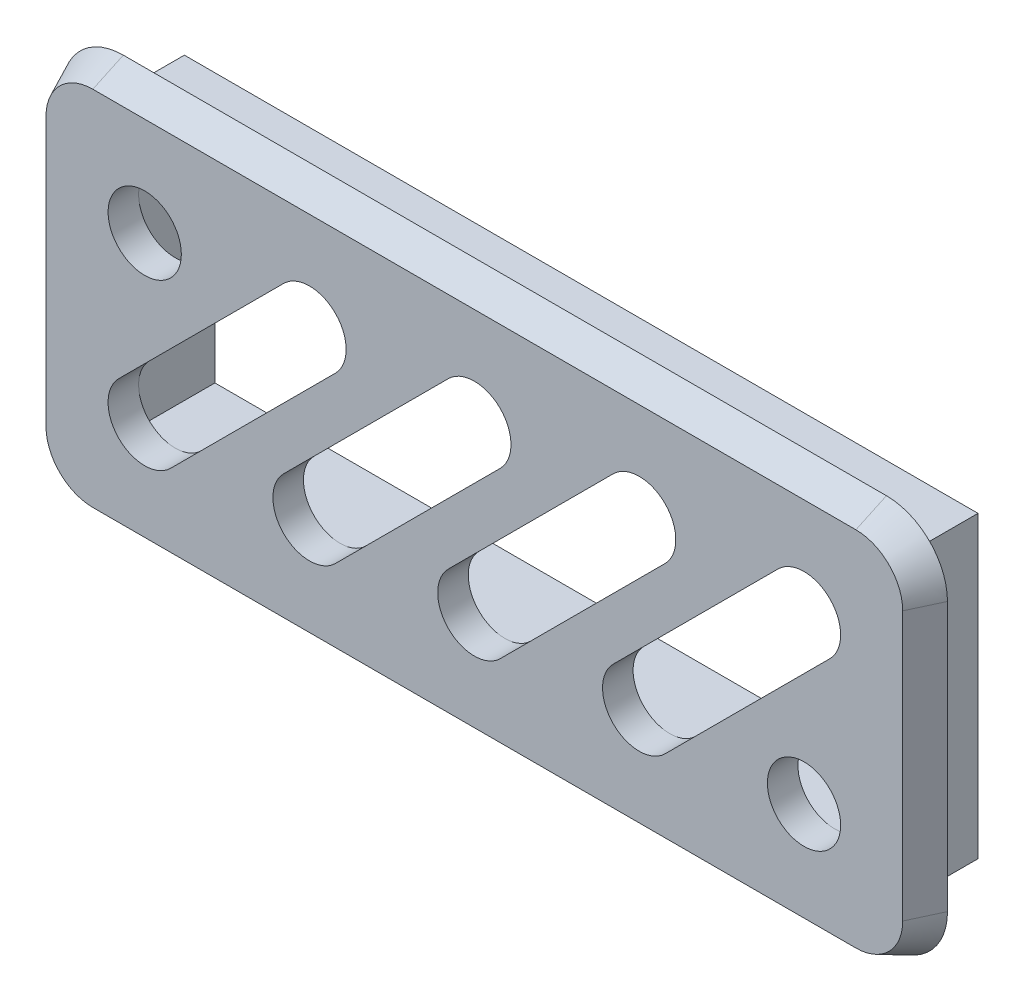
from build123d import *

# Parameters (mm, degrees)
SKETCH_1_W          = 26
SKETCH_1_H          = 9.8
SKETCH_1_W_2        = 24
SKETCH_1_H_2        = 7.8
EXTRUDE_1_DEPTH     = 2.5
EXTRUDE_2_DEPTH     = 1
EXTRUDE_2_TAPER     = 25
CUT_EXTRUDE_1_REACH = 3
SKETCH_3_R          = 1.2


with BuildPart() as part:
    # 草图1 → 凸台-拉伸1 (new body)
    with BuildSketch(Plane.XY):
        with Locations((20.66383505, -8.200793938)):
            Rectangle(SKETCH_1_W, SKETCH_1_H)
        with Locations((20.66383505, -8.200793938)):
            Rectangle(SKETCH_1_W_2, SKETCH_1_H_2, mode=Mode.SUBTRACT)
    extrude(amount=-EXTRUDE_1_DEPTH)

    # 草图2 → 凸台-拉伸2 (add)
    with BuildSketch(Plane.XY):
        with BuildLine():
            Line((35.16383505, -12.600793938), (35.16383505, -3.800793938))
            ThreePointArc((35.16383505, -3.800793938), (34.578048612, -2.386580376), (33.16383505, -1.800793938))
            Line((33.16383505, -1.800793938), (8.16383505, -1.800793938))
            ThreePointArc((8.16383505, -1.800793938), (6.749621488, -2.386580376), (6.16383505, -3.800793938))
            Line((6.16383505, -3.800793938), (6.16383505, -12.600793938))
            ThreePointArc((6.16383505, -12.600793938), (6.749621488, -14.015007501), (8.16383505, -14.600793938))
            Line((8.16383505, -14.600793938), (33.16383505, -14.600793938))
            ThreePointArc((33.16383505, -14.600793938), (34.578048612, -14.015007501), (35.16383505, -12.600793938))
        make_face()
    extrude(amount=EXTRUDE_2_DEPTH, taper=EXTRUDE_2_TAPER)

    # 草图3 → 切除-拉伸1 (cut, up to next)
    with BuildSketch(Plane(origin=(0, 0, 0), x_dir=(-1, 0, 0), z_dir=(0, 0, -1)), mode=Mode.PRIVATE) as cut_extrude_1_sk1:
        with Locations((-31.46383505, -10.900793938)):
            Circle(SKETCH_3_R)
    cut_extrude_1_tool1 = extrude(cut_extrude_1_sk1.sketch, amount=-CUT_EXTRUDE_1_REACH, mode=Mode.PRIVATE) & part.part
    add(cut_extrude_1_tool1.solids().sort_by_distance((31.463835, -10.900794, 0))[0], mode=Mode.SUBTRACT)
    # 草图3 → 切除-拉伸1 (cut, up to next)
    with BuildSketch(Plane(origin=(0, 0, 0), x_dir=(-1, 0, 0), z_dir=(0, 0, -1)), mode=Mode.PRIVATE) as cut_extrude_1_sk2:
        with Locations((-9.86383505, -5.500793938)):
            Circle(SKETCH_3_R)
    cut_extrude_1_tool2 = extrude(cut_extrude_1_sk2.sketch, amount=-CUT_EXTRUDE_1_REACH, mode=Mode.PRIVATE) & part.part
    add(cut_extrude_1_tool2.solids().sort_by_distance((9.863835, -5.500794, 0))[0], mode=Mode.SUBTRACT)
    # 草图3 → 切除-拉伸1 (cut, up to next)
    with BuildSketch(Plane(origin=(0, 0, 0), x_dir=(-1, 0, 0), z_dir=(0, 0, -1)), mode=Mode.PRIVATE) as cut_extrude_1_sk3:
        with BuildLine():
            Line((-30.615306913, -4.652265801), (-25.215306913, -10.052265801))
            ThreePointArc((-25.215306913, -10.052265801), (-25.215306913, -11.749322076), (-26.912363188, -11.749322076))
            Line((-26.912363188, -11.749322076), (-32.312363188, -6.349322076))
            ThreePointArc((-32.312363188, -6.349322076), (-32.312363188, -4.652265801), (-30.615306913, -4.652265801))
        make_face()
    cut_extrude_1_tool3 = extrude(cut_extrude_1_sk3.sketch, amount=-CUT_EXTRUDE_1_REACH, mode=Mode.PRIVATE) & part.part
    add(cut_extrude_1_tool3.solids().sort_by_distance((28.763835, -8.200794, 0))[0], mode=Mode.SUBTRACT)
    # 草图3 → 切除-拉伸1 (cut, up to next)
    with BuildSketch(Plane(origin=(0, 0, 0), x_dir=(-1, 0, 0), z_dir=(0, 0, -1)), mode=Mode.PRIVATE) as cut_extrude_1_sk4:
        with BuildLine():
            Line((-25.215306913, -4.652265801), (-19.815306913, -10.052265801))
            ThreePointArc((-19.815306913, -10.052265801), (-19.815306913, -11.749322076), (-21.512363188, -11.749322076))
            Line((-21.512363188, -11.749322076), (-26.912363188, -6.349322076))
            ThreePointArc((-26.912363188, -6.349322076), (-26.912363188, -4.652265801), (-25.215306913, -4.652265801))
        make_face()
    cut_extrude_1_tool4 = extrude(cut_extrude_1_sk4.sketch, amount=-CUT_EXTRUDE_1_REACH, mode=Mode.PRIVATE) & part.part
    add(cut_extrude_1_tool4.solids().sort_by_distance((23.363835, -8.200794, 0))[0], mode=Mode.SUBTRACT)
    # 草图3 → 切除-拉伸1 (cut, up to next)
    with BuildSketch(Plane(origin=(0, 0, 0), x_dir=(-1, 0, 0), z_dir=(0, 0, -1)), mode=Mode.PRIVATE) as cut_extrude_1_sk5:
        with BuildLine():
            Line((-19.815306913, -4.652265801), (-14.415306913, -10.052265801))
            ThreePointArc((-14.415306913, -10.052265801), (-14.415306913, -11.749322076), (-16.112363188, -11.749322076))
            Line((-16.112363188, -11.749322076), (-21.512363188, -6.349322076))
            ThreePointArc((-21.512363188, -6.349322076), (-21.512363188, -4.652265801), (-19.815306913, -4.652265801))
        make_face()
    cut_extrude_1_tool5 = extrude(cut_extrude_1_sk5.sketch, amount=-CUT_EXTRUDE_1_REACH, mode=Mode.PRIVATE) & part.part
    add(cut_extrude_1_tool5.solids().sort_by_distance((17.963835, -8.200794, 0))[0], mode=Mode.SUBTRACT)
    # 草图3 → 切除-拉伸1 (cut, up to next)
    with BuildSketch(Plane(origin=(0, 0, 0), x_dir=(-1, 0, 0), z_dir=(0, 0, -1)), mode=Mode.PRIVATE) as cut_extrude_1_sk6:
        with BuildLine():
            Line((-14.415306913, -4.652265801), (-9.015306913, -10.052265801))
            ThreePointArc((-9.015306913, -10.052265801), (-9.015306913, -11.749322076), (-10.712363188, -11.749322076))
            Line((-10.712363188, -11.749322076), (-16.112363188, -6.349322076))
            ThreePointArc((-16.112363188, -6.349322076), (-16.112363188, -4.652265801), (-14.415306913, -4.652265801))
        make_face()
    cut_extrude_1_tool6 = extrude(cut_extrude_1_sk6.sketch, amount=-CUT_EXTRUDE_1_REACH, mode=Mode.PRIVATE) & part.part
    add(cut_extrude_1_tool6.solids().sort_by_distance((12.563835, -8.200794, 0))[0], mode=Mode.SUBTRACT)


solid = part.part
